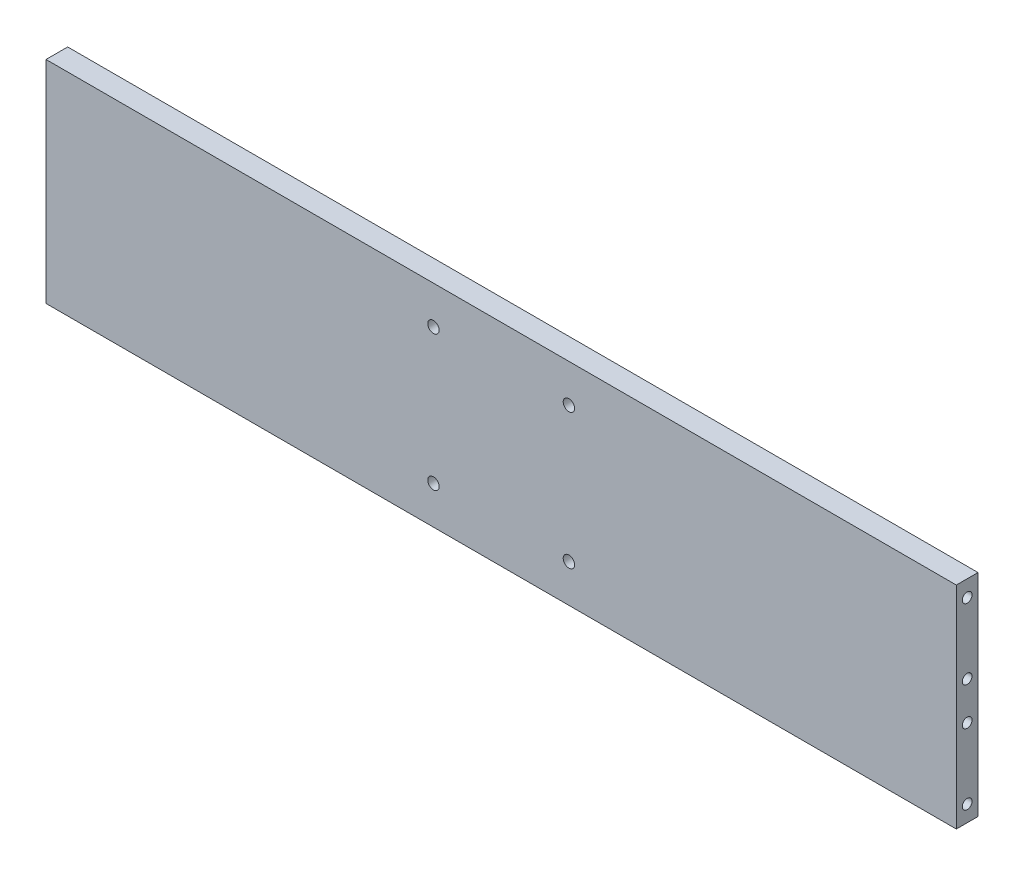
from build123d import *

# Parameters (mm, degrees)
SKETCH1_W           = 336
SKETCH1_H           = 78
SKETCH1_R           = 2.1
BOSS_EXTRUDE1_DEPTH = 8
CUT_EXTRUDE1_REACH  = 338
SKETCH2_R           = 1.8


with BuildPart() as part:
    # Sketch1 → Boss-Extrude1 (new body)
    with BuildSketch(Plane.XY):
        Rectangle(SKETCH1_W, SKETCH1_H)
        with Locations((-25, 25)):
            Circle(SKETCH1_R, mode=Mode.SUBTRACT)
        with Locations((25, 25)):
            Circle(SKETCH1_R, mode=Mode.SUBTRACT)
        with Locations((25, -25)):
            Circle(SKETCH1_R, mode=Mode.SUBTRACT)
        with Locations((-25, -25)):
            Circle(SKETCH1_R, mode=Mode.SUBTRACT)
    extrude(amount=BOSS_EXTRUDE1_DEPTH)

    # Sketch2 → Cut-Extrude1 (cut, up to next)
    with BuildSketch(Plane(origin=(168, 0, 0), x_dir=(0, 0, -1), z_dir=(1, 0, 0)), mode=Mode.PRIVATE) as cut_extrude1_sk1:
        with Locations((-4, 33)):
            Circle(SKETCH2_R)
    cut_extrude1_tool1 = extrude(cut_extrude1_sk1.sketch, amount=-CUT_EXTRUDE1_REACH, mode=Mode.PRIVATE) & part.part
    add(cut_extrude1_tool1.solids().sort_by_distance((168, 33, 4))[0], mode=Mode.SUBTRACT)
    # Sketch2 → Cut-Extrude1 (cut, up to next)
    with BuildSketch(Plane(origin=(168, 0, 0), x_dir=(0, 0, -1), z_dir=(1, 0, 0)), mode=Mode.PRIVATE) as cut_extrude1_sk2:
        with Locations((-4, 7)):
            Circle(SKETCH2_R)
    cut_extrude1_tool2 = extrude(cut_extrude1_sk2.sketch, amount=-CUT_EXTRUDE1_REACH, mode=Mode.PRIVATE) & part.part
    add(cut_extrude1_tool2.solids().sort_by_distance((168, 7, 4))[0], mode=Mode.SUBTRACT)
    # Sketch2 → Cut-Extrude1 (cut, up to next)
    with BuildSketch(Plane(origin=(168, 0, 0), x_dir=(0, 0, -1), z_dir=(1, 0, 0)), mode=Mode.PRIVATE) as cut_extrude1_sk3:
        with Locations((-4, -7)):
            Circle(SKETCH2_R)
    cut_extrude1_tool3 = extrude(cut_extrude1_sk3.sketch, amount=-CUT_EXTRUDE1_REACH, mode=Mode.PRIVATE) & part.part
    add(cut_extrude1_tool3.solids().sort_by_distance((168, -7, 4))[0], mode=Mode.SUBTRACT)
    # Sketch2 → Cut-Extrude1 (cut, up to next)
    with BuildSketch(Plane(origin=(168, 0, 0), x_dir=(0, 0, -1), z_dir=(1, 0, 0)), mode=Mode.PRIVATE) as cut_extrude1_sk4:
        with Locations((-4, -33)):
            Circle(SKETCH2_R)
    cut_extrude1_tool4 = extrude(cut_extrude1_sk4.sketch, amount=-CUT_EXTRUDE1_REACH, mode=Mode.PRIVATE) & part.part
    add(cut_extrude1_tool4.solids().sort_by_distance((168, -33, 4))[0], mode=Mode.SUBTRACT)


solid = part.part
